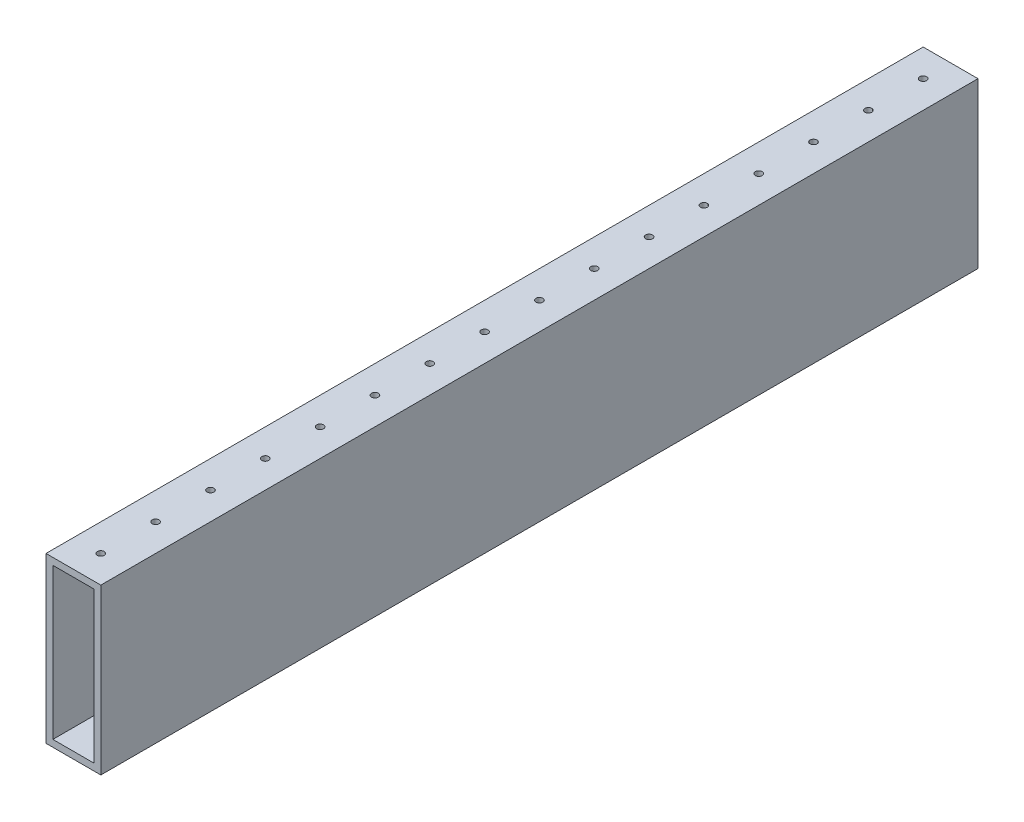
from build123d import *

# Parameters (mm, degrees)
SKETCH1_W           = 25.4
SKETCH1_H           = 76.2
BOSS_EXTRUDE1_DEPTH = 406.4
SHELL1_T            = -3.175
SKETCH2_R           = 1.5875
CUT_EXTRUDE1_DEPTH  = 3.175
LPATTERN1_COUNT     = 16
LPATTERN1_PITCH     = 25.4


with BuildPart() as part:
    # Sketch1 → Boss-Extrude1 (new body)
    with BuildSketch(Plane.XY):
        Rectangle(SKETCH1_W, SKETCH1_H)
    extrude(amount=BOSS_EXTRUDE1_DEPTH)

    # Shell1
    shell1_openings = [part.faces().sort_by_distance(p)[0] for p in [
        (0, 0, 406.4),
        (0, 0, 0),
    ]]
    offset(amount=SHELL1_T, openings=shell1_openings, kind=Kind.INTERSECTION)

    # Sketch2 → Cut-Extrude1 (cut)
    with BuildSketch(Plane(origin=(0, 38.1, 0), x_dir=(1, 0, 0), z_dir=(0, 1, 0))):
        with Locations((0, -12.7)):
            Circle(SKETCH2_R)
    cut_extrude1 = extrude(amount=-CUT_EXTRUDE1_DEPTH, mode=Mode.SUBTRACT)

    # LPattern1: Cut-Extrude1 ×16
    with Locations(*[(0, 0, i * LPATTERN1_PITCH) for i in range(1, LPATTERN1_COUNT)]):
        add(cut_extrude1, mode=Mode.SUBTRACT)


solid = part.part
